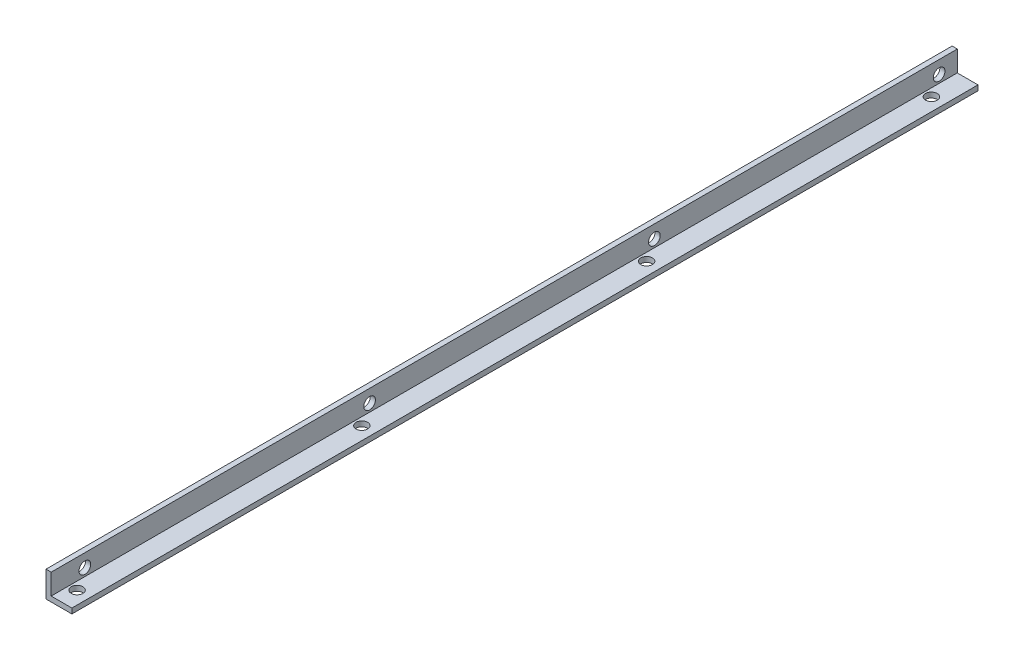
from build123d import *

# Parameters (mm, degrees)
EXTRUDE_1_DEPTH     = 350
SKETCH_2_R          = 2.25
CUT_EXTRUDE_1_DEPTH = 11
CUT_EXTRUDE_2_REACH = 12
SKETCH_3_R          = 2.25


with BuildPart() as part:
    # Эскиз1 → Бобышка-Вытянуть1 (new body)
    with BuildSketch(Plane.XY):
        Polygon((0, 0), (0, 10), (2, 10), (2, 2), (10, 2), (10, 0), align=None)
    extrude(amount=EXTRUDE_1_DEPTH)

    # Эскиз2 → Вырез-Вытянуть1 (cut, through all)
    with BuildSketch(Plane.ZY):
        with Locations((7, 5)):
            Circle(SKETCH_2_R)
        with Locations((117, 5)):
            Circle(SKETCH_2_R)
        with Locations((227, 5)):
            Circle(SKETCH_2_R)
        with Locations((337, 5)):
            Circle(SKETCH_2_R)
    extrude(amount=-CUT_EXTRUDE_1_DEPTH, mode=Mode.SUBTRACT)

    # Эскиз3 → Вырез-Вытянуть2 (cut, up to next)
    with BuildSketch(Plane.XZ, mode=Mode.PRIVATE) as cut_extrude_2_sk1:
        with Locations((5, 343)):
            Circle(SKETCH_3_R)
    cut_extrude_2_tool1 = extrude(cut_extrude_2_sk1.sketch, amount=-CUT_EXTRUDE_2_REACH, mode=Mode.PRIVATE) & part.part
    add(cut_extrude_2_tool1.solids().sort_by_distance((5, 0, 343))[0], mode=Mode.SUBTRACT)
    # Эскиз3 → Вырез-Вытянуть2 (cut, up to next)
    with BuildSketch(Plane.XZ, mode=Mode.PRIVATE) as cut_extrude_2_sk2:
        with Locations((5, 233)):
            Circle(SKETCH_3_R)
    cut_extrude_2_tool2 = extrude(cut_extrude_2_sk2.sketch, amount=-CUT_EXTRUDE_2_REACH, mode=Mode.PRIVATE) & part.part
    add(cut_extrude_2_tool2.solids().sort_by_distance((5, 0, 233))[0], mode=Mode.SUBTRACT)
    # Эскиз3 → Вырез-Вытянуть2 (cut, up to next)
    with BuildSketch(Plane.XZ, mode=Mode.PRIVATE) as cut_extrude_2_sk3:
        with Locations((5, 123)):
            Circle(SKETCH_3_R)
    cut_extrude_2_tool3 = extrude(cut_extrude_2_sk3.sketch, amount=-CUT_EXTRUDE_2_REACH, mode=Mode.PRIVATE) & part.part
    add(cut_extrude_2_tool3.solids().sort_by_distance((5, 0, 123))[0], mode=Mode.SUBTRACT)
    # Эскиз3 → Вырез-Вытянуть2 (cut, up to next)
    with BuildSketch(Plane.XZ, mode=Mode.PRIVATE) as cut_extrude_2_sk4:
        with Locations((5, 13)):
            Circle(SKETCH_3_R)
    cut_extrude_2_tool4 = extrude(cut_extrude_2_sk4.sketch, amount=-CUT_EXTRUDE_2_REACH, mode=Mode.PRIVATE) & part.part
    add(cut_extrude_2_tool4.solids().sort_by_distance((5, 0, 13))[0], mode=Mode.SUBTRACT)


solid = part.part
